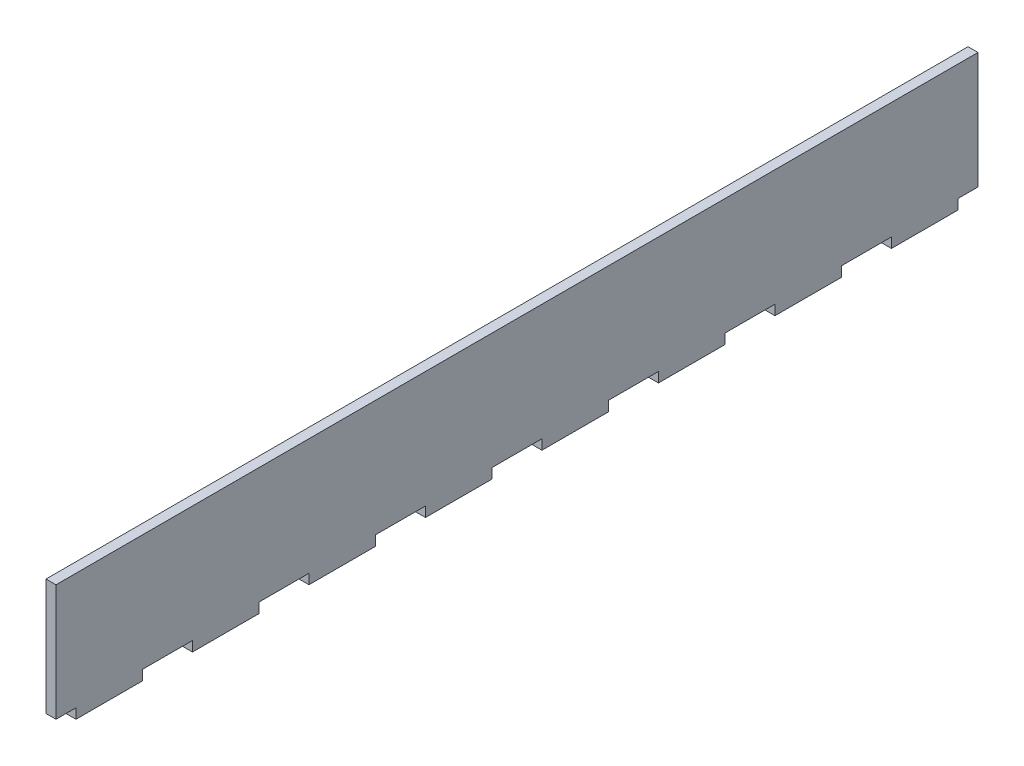
from build123d import *

# Parameters (mm, degrees)
BOSS_EXTRUDE1_DEPTH = 3


with BuildPart() as part:
    # Sketch1 → Boss-Extrude1 (new body)
    with BuildSketch(Plane(origin=(0, 0, 0), x_dir=(0, 0, -1), z_dir=(1, 0, 0))):
        Polygon((26, 0), (41, 0), (41, -3), (61, -3), (61, 0), (76, 0), (76, -3), (96, -3), (96, 0), (111, 0), (111, -3), (131, -3), (131, 0), (146, 0), (146, -3), (166, -3), (166, 0), (181, 0), (181, -3), (201, -3), (201, 0), (216, 0), (216, -3), (236, -3), (236, 0), (251, 0), (251, -3), (271, -3), (271, 0), (277, 0), (277, 35), (0, 35), (0, 0), (6, 0), (6, -3), (26, -3), align=None)
    extrude(amount=BOSS_EXTRUDE1_DEPTH)


solid = part.part
